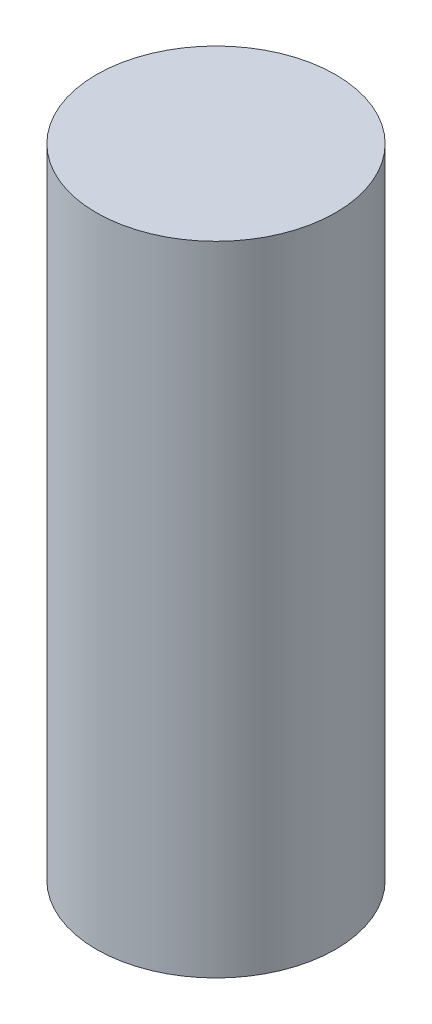
from build123d import *

# Parameters (mm, degrees)
SKETCH1_R           = 38.1
BOSS_EXTRUDE1_DEPTH = 203.2


with BuildPart() as part:
    # Sketch1 → Boss-Extrude1 (new body)
    with BuildSketch(Plane(origin=(0, 0, 0), x_dir=(1, 0, 0), z_dir=(0, 1, 0))):
        Circle(SKETCH1_R)
    extrude(amount=BOSS_EXTRUDE1_DEPTH)


solid = part.part
